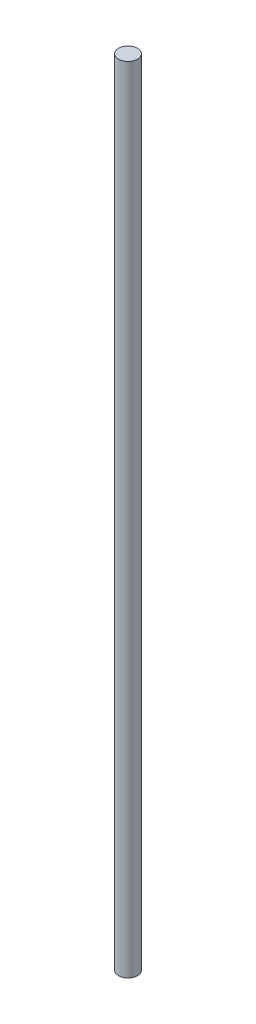
from build123d import *

# Parameters (mm, degrees)
SKETCH1_W = 4
SKETCH1_H = 335


with BuildPart() as part:
    # Sketch1 → Revolve1 (revolve)
    with BuildSketch(Plane.XY):
        with Locations((2, 0)):
            Rectangle(SKETCH1_W, SKETCH1_H)
    revolve(axis=Axis((0, 167.5, 0), (0, -1, 0)))


solid = part.part
